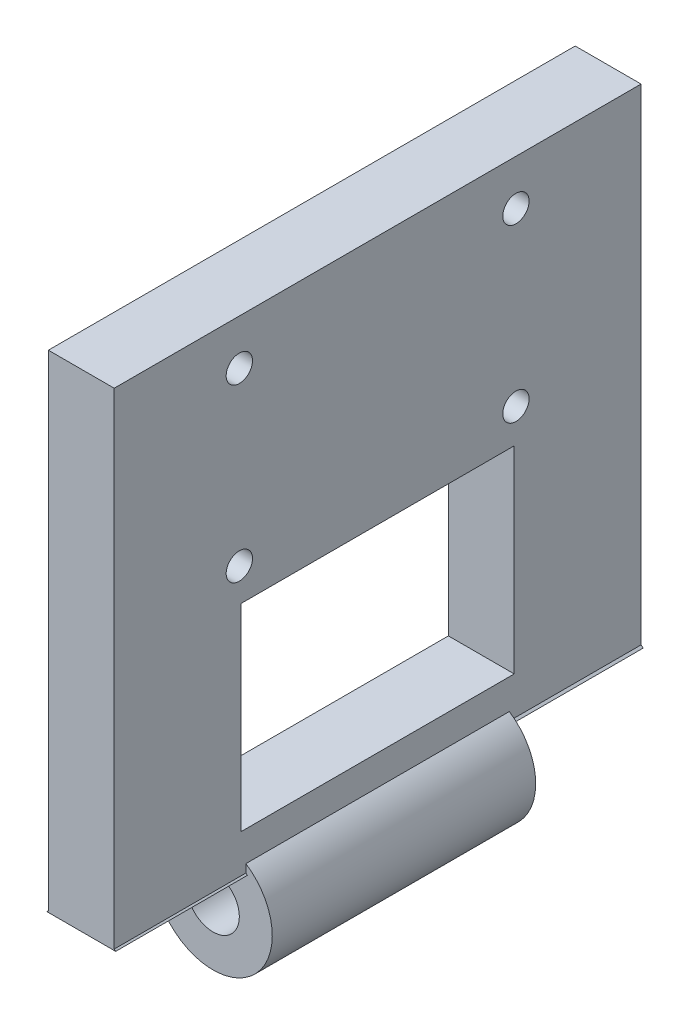
from build123d import *

# Parameters (mm, degrees)
SKETCH1_W           = 40
SKETCH1_H           = 40
BOSS_EXTRUDE1_DEPTH = 5
SKETCH2_R           = 4
SKETCH2_R_2         = 1.5
BOSS_EXTRUDE2_DEPTH = 40
SKETCH4_R           = 1.5
CUT_EXTRUDE1_DEPTH  = 40
SKETCH5_W           = 9.64553252
SKETCH5_H           = 8.977750056
CUT_EXTRUDE3_DEPTH  = 10
SKETCH6_W           = 13.188128002
SKETCH6_H           = 14.056051126
CUT_EXTRUDE4_DEPTH  = 10
SKETCH8_R           = 1
CUT_EXTRUDE5_DEPTH  = 7.5
SKETCH9_W           = 20.740982478
SKETCH9_H           = 15
CUT_EXTRUDE6_DEPTH  = 7.5
SKETCH16_R          = 4.5
BOSS_EXTRUDE3_DEPTH = 20
SKETCH17_R          = 2
CUT_EXTRUDE7_DEPTH  = 20


with BuildPart() as part:
    # Sketch1 → Boss-Extrude1 (new body)
    with BuildSketch(Plane(origin=(0, 0, 0), x_dir=(0, 0, -1), z_dir=(1, 0, 0))):
        Rectangle(SKETCH1_W, SKETCH1_H)
    extrude(amount=BOSS_EXTRUDE1_DEPTH)

    # Sketch2 → Boss-Extrude2 (add)
    with BuildSketch(Plane.XY.offset(20)):
        with Locations((2.5, -20)):
            Circle(SKETCH2_R)
        with Locations((2.5, -20)):
            Circle(SKETCH2_R_2, mode=Mode.SUBTRACT)
    extrude(amount=-BOSS_EXTRUDE2_DEPTH)

    # Sketch4 → Cut-Extrude1 (cut)
    with BuildSketch(Plane.XY.offset(20)):
        with Locations((2.5, -20)):
            Circle(SKETCH4_R)
    extrude(amount=-CUT_EXTRUDE1_DEPTH, mode=Mode.SUBTRACT)

    # Sketch5 → Cut-Extrude3 (cut)
    with BuildSketch(Plane(origin=(0, 0, -20), x_dir=(-1, 0, 0), z_dir=(0, 0, -1))):
        with Locations((-2.5, -21.5)):
            Rectangle(SKETCH5_W, SKETCH5_H)
    extrude(amount=-CUT_EXTRUDE3_DEPTH, mode=Mode.SUBTRACT)

    # Sketch6 → Cut-Extrude4 (cut)
    with BuildSketch(Plane.XY.offset(20)):
        with Locations((2.5, -24)):
            Rectangle(SKETCH6_W, SKETCH6_H)
    extrude(amount=-CUT_EXTRUDE4_DEPTH, mode=Mode.SUBTRACT)

    # Sketch8 → Cut-Extrude5 (cut, through all)
    with BuildSketch(Plane(origin=(5, 0, 0), x_dir=(0, 0, -1), z_dir=(1, 0, 0))):
        with Locations((-10.5, 16.5612495)):
            Circle(SKETCH8_R)
        with Locations((10.5, 16.5612495)):
            Circle(SKETCH8_R)
        with Locations((10.5, 3.5612495)):
            Circle(SKETCH8_R)
        with Locations((-10.5, 3.5612495)):
            Circle(SKETCH8_R)
    extrude(amount=-CUT_EXTRUDE5_DEPTH, mode=Mode.SUBTRACT)

    # Sketch9 → Cut-Extrude6 (cut, through all)
    with BuildSketch(Plane(origin=(5, 0, 0), x_dir=(0, 0, -1), z_dir=(1, 0, 0))):
        with Locations((0, -6.471626191)):
            Rectangle(SKETCH9_W, SKETCH9_H)
    extrude(amount=-CUT_EXTRUDE6_DEPTH, mode=Mode.SUBTRACT)

    # Sketch16 → Boss-Extrude3 (add)
    with BuildSketch(Plane.XY.offset(10)):
        with Locations((2.5, -20)):
            Circle(SKETCH16_R)
    extrude(amount=-BOSS_EXTRUDE3_DEPTH)

    # Sketch17 → Cut-Extrude7 (cut)
    with BuildSketch(Plane.XY.offset(10)):
        with Locations((2.5, -20)):
            Circle(SKETCH17_R)
    extrude(amount=-CUT_EXTRUDE7_DEPTH, mode=Mode.SUBTRACT)


solid = part.part
